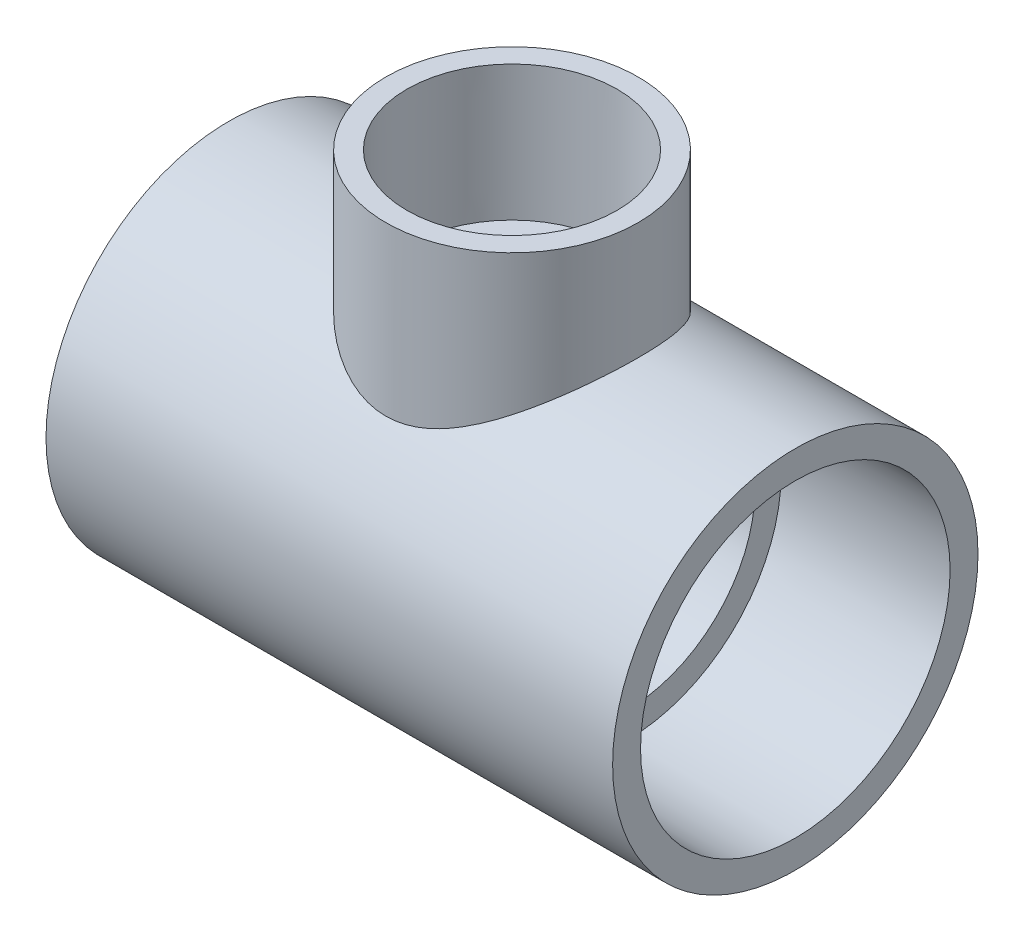
from build123d import *

# Parameters (mm, degrees)
SKETCH4_R           = 52.705
BOSS_EXTRUDE1_DEPTH = 66.5988
SKETCH5_R           = 36.4109
BOSS_EXTRUDE2_DEPTH = 47.625


with BuildPart() as part:
    # Sketch1 → Revolve1 (revolve)
    with BuildSketch(Plane.XY):
        Polygon((-81.7372, -52.705), (-33.2994, -52.705), (-33.2994, -44.3484), (-81.7372, -44.6532), align=None)
        Polygon((81.7372, -44.6532), (33.2994, -44.3484), (33.2994, -52.705), (81.7372, -52.705), align=None)
    revolve(axis=Axis((-81.7372, 0, 0), (1, 0, 0)))



with BuildPart() as body_2:
    # Sketch2 → Revolve2 (revolve)
    with BuildSketch(Plane.XY):
        Polygon((30.3149, 86.4616), (30.0863, 47.625), (36.4109, 47.625), (36.4109, 86.4616), align=None)
    revolve(axis=Axis((0, 0, 0), (0, 1, 0)))


with BuildPart() as part_1:
    add(part.part)

    add(body_2.part)  # Boss-Extrude1 merges body 2
    # Sketch4 → Boss-Extrude1 (add)
    with BuildSketch(Plane(origin=(-33.2994, 0, 0), x_dir=(0, 0, -1), z_dir=(1, 0, 0))):
        Circle(SKETCH4_R)
    extrude(amount=BOSS_EXTRUDE1_DEPTH)

    # Sketch5 → Boss-Extrude2 (add)
    with BuildSketch(Plane.XZ.offset(-47.625)):
        Circle(SKETCH5_R)
    extrude(amount=BOSS_EXTRUDE2_DEPTH)

    # Sketch6 → Cut-Revolve1 (revolve, cut)
    with BuildSketch(Plane.XY):
        Polygon((-81.7372, -44.6532), (-33.2994, -44.3484), (-33.2994, -36.83), (33.2994, -36.83), (33.2994, -44.3484), (81.7372, -44.6532), (81.7372, 0), (-81.7372, 0), align=None)
    revolve(axis=Axis((81.7372, 0, 0), (-1, 0, 0)), mode=Mode.SUBTRACT)

    # Sketch7 → Cut-Revolve2 (revolve, cut)
    with BuildSketch(Plane.XY):
        Polygon((30.3149, 86.4616), (30.0863, 47.625), (24.6253, 47.625), (24.6253, 0), (0, 0), (0, 86.4616), align=None)
    revolve(axis=Axis((0, 0, 0), (0, 1, 0)), mode=Mode.SUBTRACT)


solid = part_1.part
